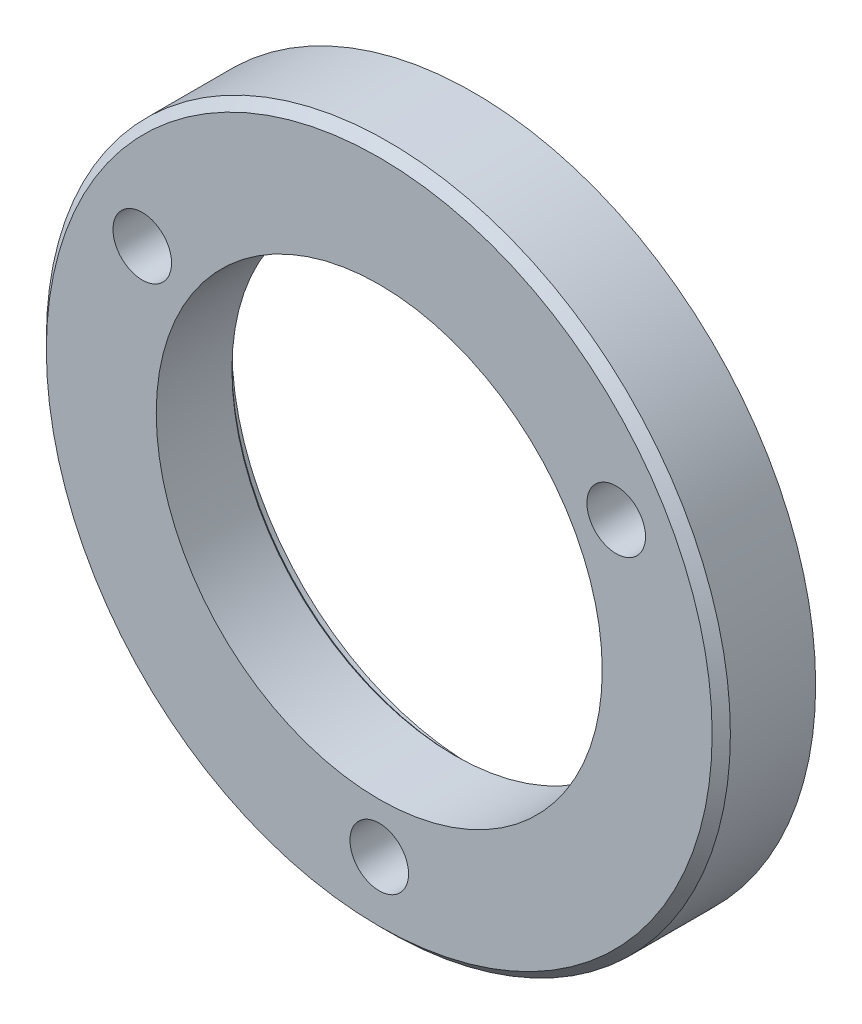
from build123d import *

# Parameters (mm, degrees)
SKETCH1_R             = 19.05
SKETCH1_R_2           = 12.4206
BOSS_EXTRUDE1_DEPTH   = 4.3688
SKETCH4_R             = 19.05
SKETCH4_R_2           = 13.462
BOSS_EXTRUDE2_DEPTH   = 0.889
F_4_CLEARANCE_HOLE1_D = 3.2639
CHAMFER1_SIZE         = 0.1524
CHAMFER2_SIZE         = 0.508


with BuildPart() as part:
    # Sketch1 → Boss-Extrude1 (new body)
    with BuildSketch(Plane.XY):
        with Locations((-8.514490438, 61.389045102)):
            Circle(SKETCH1_R)
        with Locations((-8.514490438, 61.389045102)):
            Circle(SKETCH1_R_2, mode=Mode.SUBTRACT)
    extrude(amount=BOSS_EXTRUDE1_DEPTH)

    # Sketch4 → Boss-Extrude2 (add)
    with BuildSketch(Plane(origin=(0, 0, 0), x_dir=(-1, 0, 0), z_dir=(0, 0, -1))):
        with Locations((8.514490438, 61.389045102)):
            Circle(SKETCH4_R)
        with Locations((8.514490438, 61.389045102)):
            Circle(SKETCH4_R_2, mode=Mode.SUBTRACT)
    extrude(amount=BOSS_EXTRUDE2_DEPTH)

    # #4 Clearance Hole1 (through all)
    with Locations(Plane(origin=(-12.913159706, 9.247820606, 4.3688), x_dir=(1, 0, 0), z_dir=(0, 0, 1))):
        with Locations((17.596896421, 59.80259772), (-8.799557886, 59.80259772), (4.398669267, 36.94259772)):
            Hole(F_4_CLEARANCE_HOLE1_D / 2)

    # Chamfer1
    chamfer1_edges = [part.edges().sort_by_distance(p)[0] for p in [
        (-20.935090438, 61.389045102, 0),
    ]]
    chamfer(chamfer1_edges, length=CHAMFER1_SIZE)

    # Chamfer2
    chamfer2_edges = [part.edges().sort_by_distance(p)[0] for p in [
        (-27.564490438, 61.389045102, 4.3688),
    ]]
    chamfer(chamfer2_edges, length=CHAMFER2_SIZE)


solid = part.part
